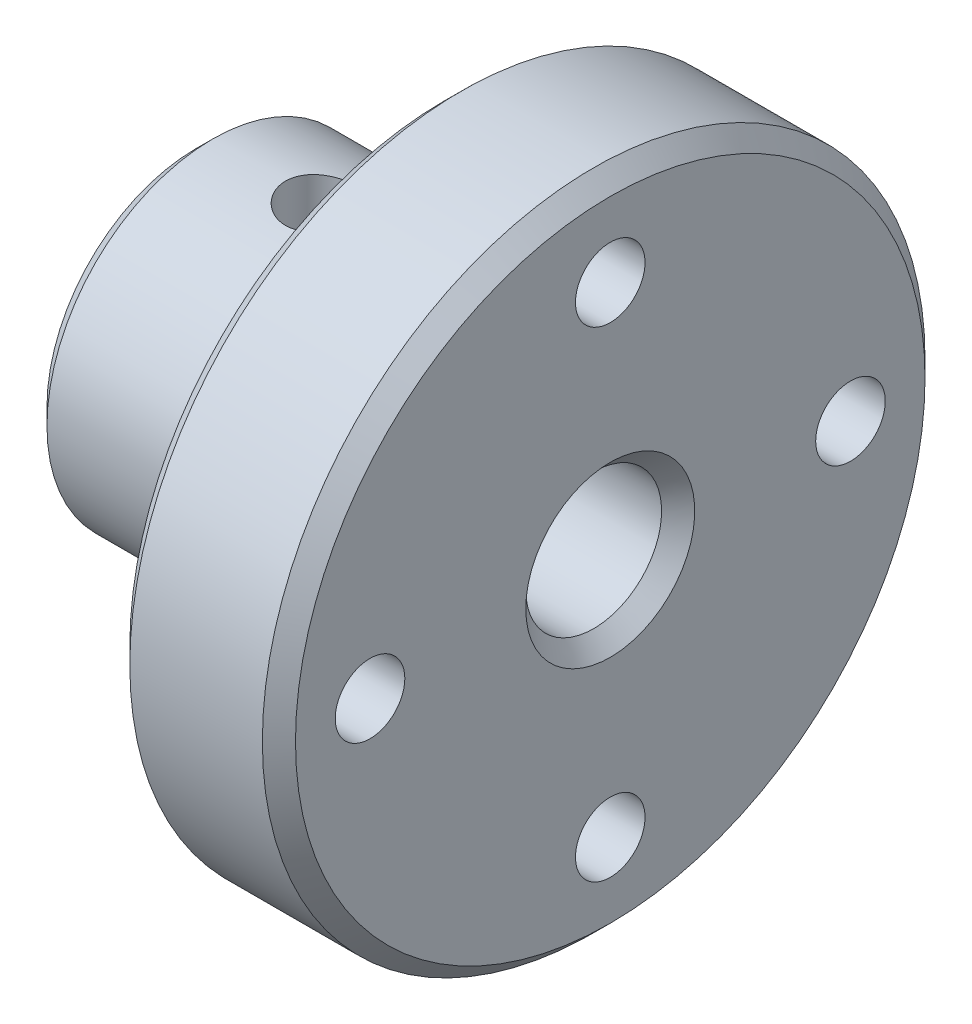
from build123d import *

# Parameters (mm, degrees)
M5X0_8_TAPPED_HOLE1_D = 4.2
CIRPATTERN1_COUNT     = 4
SKETCH6_W             = 2.1
SKETCH6_H             = 20
CIRPATTERN2_COUNT     = 2
CIRPATTERN2_ANGLE     = 90
CHAMFER1_SIZE         = 1


with BuildPart() as part:
    # Sketch1 → Revolve1 (revolve)
    with BuildSketch(Plane.XY):
        Polygon((0, 4.1), (0, 10), (15, 10), (15, 20), (25, 20), (25, 4.1), align=None)
    revolve(axis=Axis((0, 0, 0), (1, 0, 0)))

    # M5x0.8 Tapped Hole1 (through all)
    with Locations(Plane(origin=(25, 0, 0), x_dir=(0, 0, -1), z_dir=(1, 0, 0))):
        with Locations((-14.5, 0)):
            m5x0_8_tapped_hole1 = Hole(M5X0_8_TAPPED_HOLE1_D / 2)

    # CirPattern1: M5x0.8 Tapped Hole1 ×4 about axis
    cirpattern1_axis = Axis((0, 0, 0), (1, 0, 0))
    for i in range(1, CIRPATTERN1_COUNT):
        add(m5x0_8_tapped_hole1.rotate(cirpattern1_axis, i * 360 / CIRPATTERN1_COUNT), mode=Mode.SUBTRACT)

    # Sketch6 → M5x0.8 Tapped Hole2 (revolve, cut)
    with BuildSketch(Plane(origin=(7.5, 0, 0), x_dir=(0, 0, -1), z_dir=(1, 0, 0))):
        with Locations((1.05, 10)):
            Rectangle(SKETCH6_W, SKETCH6_H)
    m5x0_8_tapped_hole2 = revolve(axis=Axis((7.5, -6.35, 0), (0, 1, 0)), mode=Mode.SUBTRACT)

    # CirPattern2: M5x0.8 Tapped Hole2 ×2 about axis
    cirpattern2_axis = Axis((25, 0, 0), (-1, 0, 0))
    for i in range(1, CIRPATTERN2_COUNT):
        add(m5x0_8_tapped_hole2.rotate(cirpattern2_axis, i * CIRPATTERN2_ANGLE / (CIRPATTERN2_COUNT - 1)), mode=Mode.SUBTRACT)

    # Chamfer1
    chamfer1_edges = [part.edges().sort_by_distance(p)[0] for p in [
        (25, -4.1, 0),
        (25, -20, 0),
        (15, -20, 0),
        (0, -10, 0),
        (0, -4.1, 0),
    ]]
    chamfer(chamfer1_edges, length=CHAMFER1_SIZE)


solid = part.part
